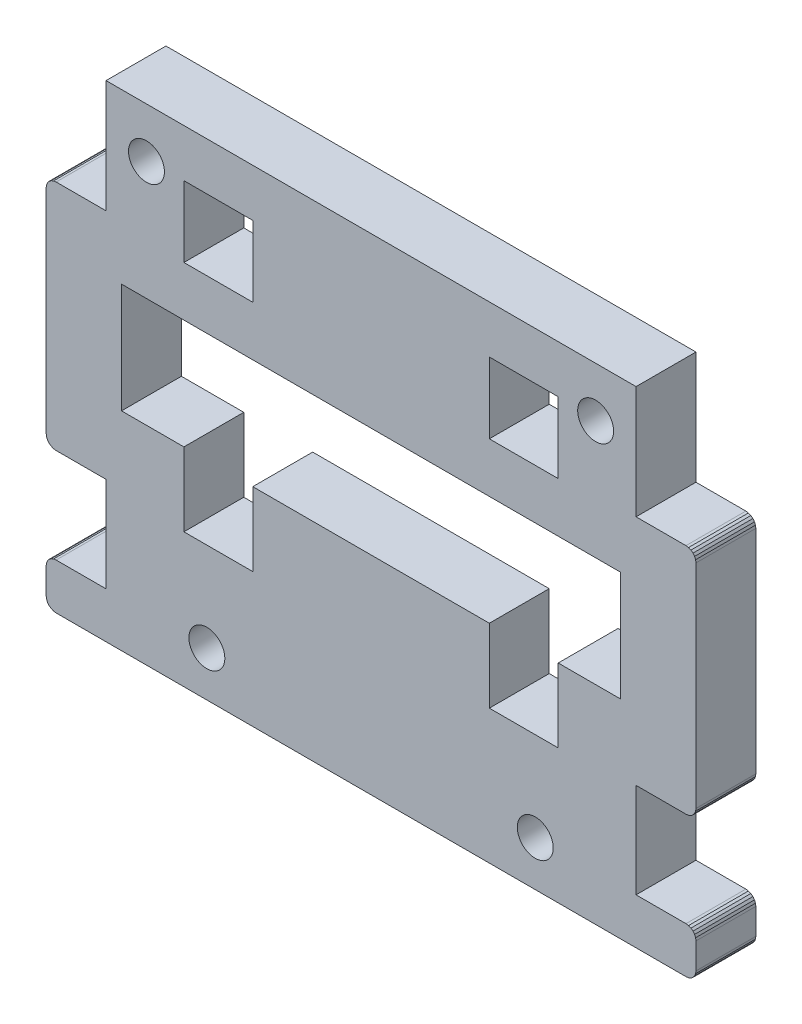
from build123d import *

# Parameters (mm, degrees)
MODEL_R                  = 1.8
MODEL_W                  = 6.9
MODEL_H                  = 7.1
RESSALTO_EXTRUS_O1_DEPTH = 6


with BuildPart() as part:
    # Model → Ressalto-extrusão1 (new body)
    with BuildSketch(Plane.XY):
        Polygon((98.034292433, 10.612136161), (98.134192856, 10.370955206), (98.16826703, 10.112136161), (98.16826703, 7.512443376), (98.134192856, 7.25362433), (98.034292433, 7.012443376), (97.875373811, 6.805336594), (97.66826703, 6.646417972), (97.427086075, 6.546517549), (97.16826703, 6.512443376), (34.067480382, 6.516377235), (33.808814837, 6.550620973), (33.567812927, 6.650613857), (33.360882181, 6.809548321), (33.202110548, 7.016604029), (33.102307278, 7.257684523), (33.06826703, 7.516376926), (33.06826703, 10.110713257), (33.102341203, 10.369532302), (33.202241626, 10.610713257), (33.361160249, 10.817820038), (33.56826703, 10.97673866), (33.809447985, 11.076639083), (34.06826703, 11.110713257), (39.06826703, 11.110713257), (39.06826703, 20.610713257), (34.06826703, 20.610713257), (33.809447985, 20.64478743), (33.56826703, 20.744687853), (33.361160249, 20.903606475), (33.202241626, 21.110713257), (33.102341203, 21.351894212), (33.06826703, 21.610713257), (33.06826703, 42.910713257), (33.102341203, 43.169532302), (33.202241626, 43.410713257), (33.361160249, 43.617820038), (33.56826703, 43.77673866), (33.809447985, 43.876639083), (34.06826703, 43.910713257), (39.06826703, 43.910713257), (39.06826703, 55.210713257), (92.16826703, 55.210713257), (92.16826703, 43.910713257), (97.16826703, 43.910713257), (97.427086075, 43.876639083), (97.66826703, 43.77673866), (97.875373811, 43.617820038), (98.034292433, 43.410713257), (98.134192856, 43.169532302), (98.16826703, 42.910713257), (98.16826703, 21.610713257), (98.134192856, 21.351894212), (98.034292433, 21.110713257), (97.875373811, 20.903606475), (97.66826703, 20.744687853), (97.427086075, 20.64478743), (97.16826703, 20.610713257), (92.16826703, 20.610713257), (92.16826703, 11.112136161), (97.16826703, 11.112136161), (97.427086075, 11.078061987), (97.66826703, 10.978161564), (97.875373811, 10.819242942), align=None)
        with Locations((49.16826703, 11.028176846)):
            Circle(MODEL_R, mode=Mode.SUBTRACT)
        with Locations((82.06826703, 11.028176846)):
            Circle(MODEL_R, mode=Mode.SUBTRACT)
        with Locations((88.11826703, 50.210713257)):
            Circle(MODEL_R, mode=Mode.SUBTRACT)
        with Locations((43.11826703, 50.210713257)):
            Circle(MODEL_R, mode=Mode.SUBTRACT)
        with Locations((80.91826703, 46.878174347)):
            Rectangle(MODEL_W, MODEL_H, mode=Mode.SUBTRACT)
        Polygon((53.76826703, 27.328179344), (53.76826703, 19.959715186), (46.86826703, 19.959715186), (46.86826703, 27.328179344), (40.618277181, 27.328179344), (40.618277181, 38.328174347), (90.618256879, 38.328174347), (90.618256879, 27.328179344), (84.36826703, 27.328179344), (84.36826703, 19.959715186), (77.46826703, 19.959715186), (77.46826703, 27.328179344), align=None, mode=Mode.SUBTRACT)
        with Locations((50.31826703, 46.878174347)):
            Rectangle(MODEL_W, MODEL_H, mode=Mode.SUBTRACT)
    extrude(amount=RESSALTO_EXTRUS_O1_DEPTH)


solid = part.part
